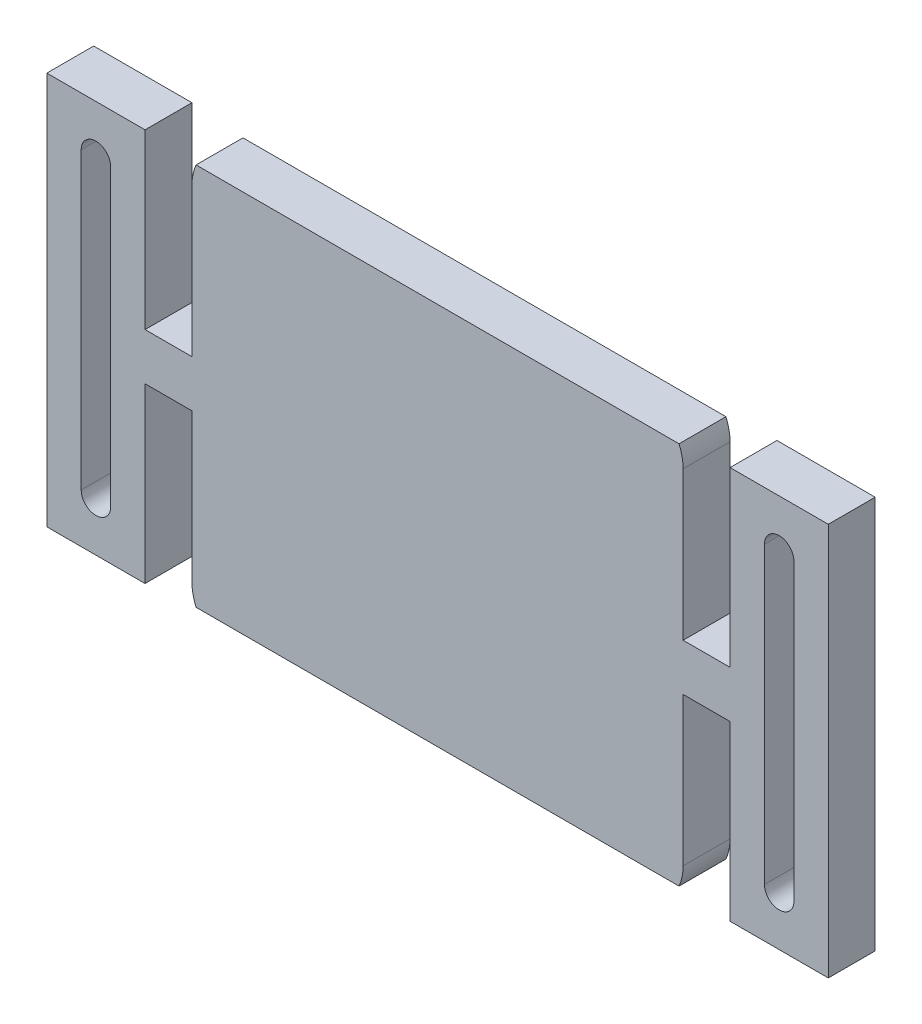
from build123d import *

# Parameters (mm, degrees)
BOSS_EXTRUDE1_DEPTH = 4.7752
CUT_EXTRUDE1_DEPTH  = 83.976265734
CUT_EXTRUDE2_DEPTH  = 10


with BuildPart() as part:
    # Sketch1 → Boss-Extrude1 (new body)
    with BuildSketch(Plane.XY):
        with BuildLine():
            Line((0, 24.8876), (-4.7752, 24.8876))
            Line((-4.7752, 24.8876), (-4.7752, 40))
            ThreePointArc((-4.7752, 40), (-6.239666094, 43.535533906), (-9.7752, 45))
            Line((-9.7752, 45), (-49.7752, 45))
            ThreePointArc((-49.7752, 45), (-53.310733906, 43.535533906), (-54.7752, 40))
            Line((-54.7752, 40), (-54.7752, 24.8876))
            Line((-54.7752, 24.8876), (-59.5504, 24.8876))
            Line((-59.5504, 24.8876), (-59.5504, 42.5))
            Line((-59.5504, 42.5), (-69.5504, 42.5))
            Line((-69.5504, 42.5), (-69.5504, 2.5))
            Line((-69.5504, 2.5), (-59.5504, 2.5))
            Line((-59.5504, 2.5), (-59.5504, 20.1124))
            Line((-59.5504, 20.1124), (-54.7752, 20.1124))
            Line((-54.7752, 20.1124), (-54.7752, 5))
            ThreePointArc((-54.7752, 5), (-53.310733906, 1.464466094), (-49.7752, 0))
            Line((-49.7752, 0), (-9.7752, 0))
            ThreePointArc((-9.7752, 0), (-6.239666094, 1.464466094), (-4.7752, 5))
            Line((-4.7752, 5), (-4.7752, 20.1124))
            Line((-4.7752, 20.1124), (0, 20.1124))
            Line((0, 20.1124), (0, 2.5))
            Line((0, 2.5), (10, 2.5))
            Line((10, 2.5), (10, 42.5))
            Line((10, 42.5), (0, 42.5))
            Line((0, 42.5), (0, 24.8876))
        make_face()
    extrude(amount=BOSS_EXTRUDE1_DEPTH)

    # Sketch1_3 → Cut-Extrude1 (cut, through all)
    with BuildSketch(Plane.XY):
        with BuildLine():
            Line((-63.0504, 7.5), (-63.0504, 37.5))
            ThreePointArc((-63.0504, 37.5), (-64.5504, 39), (-66.0504, 37.5))
            Line((-66.0504, 37.5), (-66.0504, 7.5))
            ThreePointArc((-66.0504, 7.5), (-64.5504, 6), (-63.0504, 7.5))
        make_face()
        with BuildLine():
            Line((6.5, 7.5), (6.5, 37.5))
            ThreePointArc((6.5, 37.5), (5, 39), (3.5, 37.5))
            Line((3.5, 37.5), (3.5, 7.5))
            ThreePointArc((3.5, 7.5), (5, 6), (6.5, 7.5))
        make_face()
    extrude(amount=CUT_EXTRUDE1_DEPTH, mode=Mode.SUBTRACT)

    # Sketch1_5 → Cut-Extrude2 (cut)
    with BuildSketch(Plane.XY):
        with BuildLine():
            ThreePointArc((-5.192624305, 42), (-7.036587212, 44.183300133), (-9.7752, 45))
            Line((-9.7752, 45), (-49.7752, 45))
            ThreePointArc((-49.7752, 45), (-52.513812788, 44.183300133), (-54.357775695, 42))
            Line((-54.357775695, 42), (-5.192624305, 42))
        make_face()
        with BuildLine():
            ThreePointArc((-9.7752, 0), (-7.036587212, 0.816699867), (-5.192624305, 3))
            Line((-5.192624305, 3), (-54.357775695, 3))
            ThreePointArc((-54.357775695, 3), (-52.513812788, 0.816699867), (-49.7752, 0))
            Line((-49.7752, 0), (-9.7752, 0))
        make_face()
    extrude(amount=CUT_EXTRUDE2_DEPTH, mode=Mode.SUBTRACT)


solid = part.part
